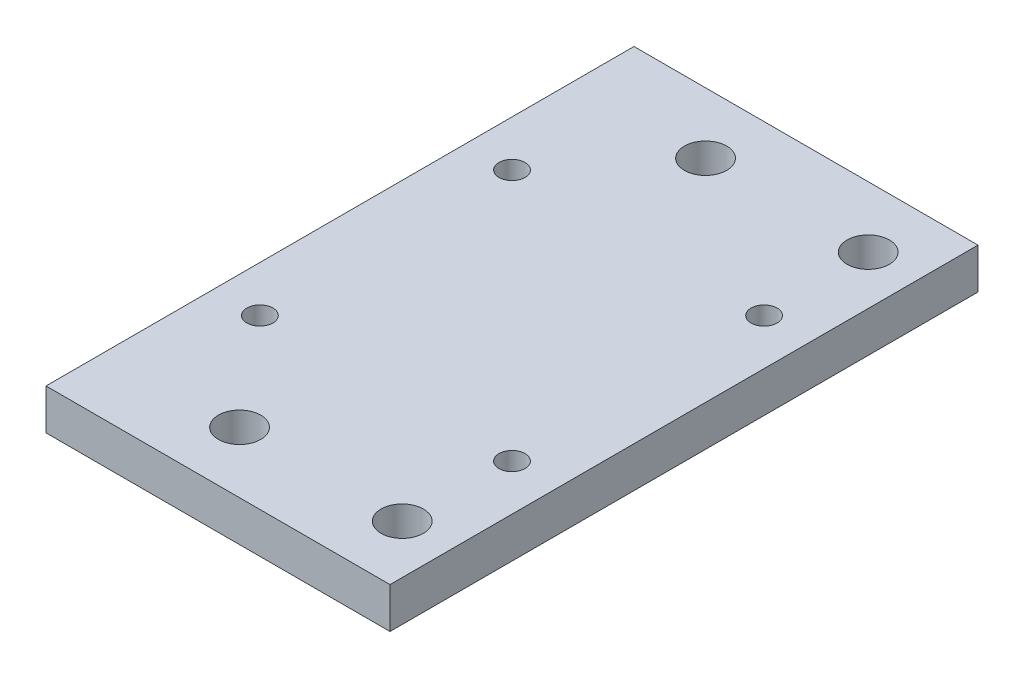
from build123d import *

# Parameters (mm, degrees)
SKETCH2_W           = 42.3
SKETCH2_H           = 42.3
SKETCH2_R           = 1.6
SKETCH2_H_2         = 15
SKETCH2_R_2         = 2.6
BOSS_EXTRUDE1_DEPTH = 5


with BuildPart() as part:
    # Sketch2 → Boss-Extrude1 (new body)
    with BuildSketch(Plane(origin=(0, 0, 0), x_dir=(1, 0, 0), z_dir=(0, 1, 0))):
        Rectangle(SKETCH2_W, SKETCH2_H)
        with Locations((-15.5, -15.5)):
            Circle(SKETCH2_R, mode=Mode.SUBTRACT)
        with Locations((15.5, 15.5)):
            Circle(SKETCH2_R, mode=Mode.SUBTRACT)
        with Locations((15.5, -15.5)):
            Circle(SKETCH2_R, mode=Mode.SUBTRACT)
        with Locations((-15.5, 15.5)):
            Circle(SKETCH2_R, mode=Mode.SUBTRACT)
        with Locations((0, -28.65)):
            Rectangle(SKETCH2_W, SKETCH2_H_2)
        with Locations((15.15, -28.65)):
            Circle(SKETCH2_R_2, mode=Mode.SUBTRACT)
        with Locations((-4.85, -28.65)):
            Circle(SKETCH2_R_2, mode=Mode.SUBTRACT)
        with Locations((0, 28.65)):
            Rectangle(SKETCH2_W, SKETCH2_H_2)
        with Locations((15.15, 28.65)):
            Circle(SKETCH2_R_2, mode=Mode.SUBTRACT)
        with Locations((-4.85, 28.65)):
            Circle(SKETCH2_R_2, mode=Mode.SUBTRACT)
    extrude(amount=BOSS_EXTRUDE1_DEPTH)


solid = part.part
